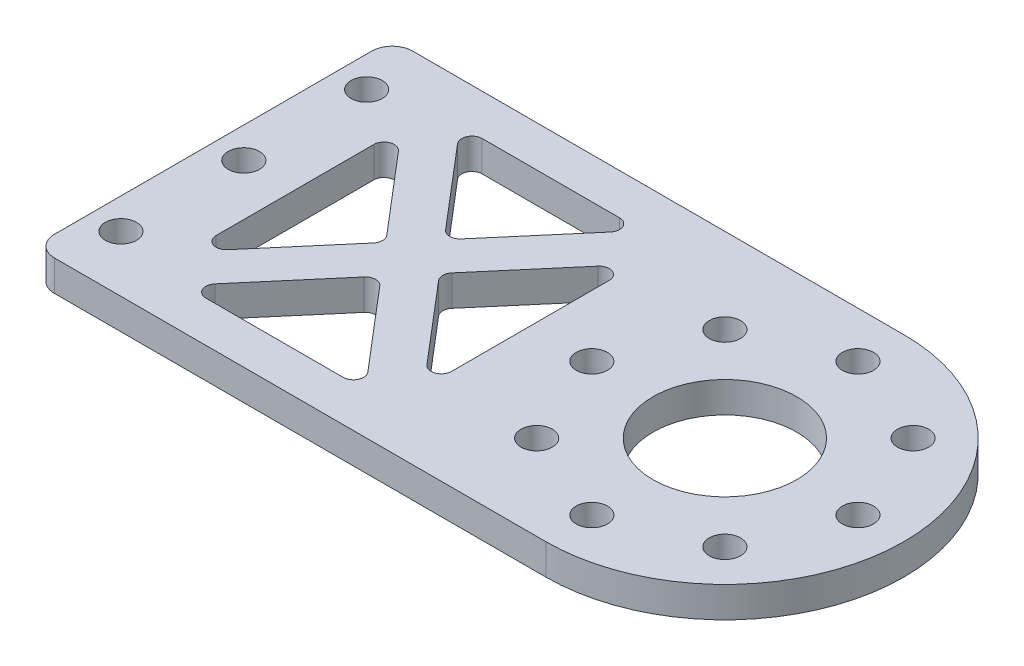
from build123d import *

# Parameters (mm, degrees)
EXTRUDE_1_DEPTH     = 3
SKETCH_2_R          = 7.025
CUT_EXTRUDE_1_DEPTH = 4
SKETCH_4_R          = 1.525
CUT_EXTRUDE_3_DEPTH = 4
FILLET_2_R          = 2
CUT_EXTRUDE_6_DEPTH = 4
SKETCH_10_R         = 1.525
CUT_EXTRUDE_8_DEPTH = 4
FILLET_7_R          = 1


with BuildPart() as part:
    # 草图1 → 凸台-拉伸1 (new body)
    with BuildSketch(Plane(origin=(0, 0, 0), x_dir=(1, 0, 0), z_dir=(0, 1, 0))):
        with BuildLine():
            Line((-25, 17.5), (-25, -17.5))
            Line((-25, -17.5), (25, -17.5))
            ThreePointArc((25, -17.5), (7.5, 0), (25, 17.5))
            Line((25, 17.5), (-25, 17.5))
        make_face()
        with BuildLine():
            ThreePointArc((25, 17.5), (7.5, 0), (25, -17.5))
            Line((25, -17.5), (25, 17.5))
        make_face()
        with BuildLine():
            Line((25, 17.5), (25, -17.5))
            ThreePointArc((25, -17.5), (37.374368671, -12.374368671), (42.5, 0))
            ThreePointArc((42.5, 0), (37.374368671, 12.374368671), (25, 17.5))
        make_face()
    extrude(amount=EXTRUDE_1_DEPTH)

    # 草图2 → 切除-拉伸1 (cut, through all)
    with BuildSketch(Plane(origin=(0, 3, 0), x_dir=(1, 0, 0), z_dir=(0, 1, 0))):
        with Locations((25, 0)):
            Circle(SKETCH_2_R)
    extrude(amount=-CUT_EXTRUDE_1_DEPTH, mode=Mode.SUBTRACT)

    # 草图4 → 切除-拉伸3 (cut, through all)
    with BuildSketch(Plane(origin=(0, 3, 0), x_dir=(1, 0, 0), z_dir=(0, 1, 0))):
        with Locations((25, 13)):
            Circle(SKETCH_4_R)
        with Locations((34.192388155, 9.192388155)):
            Circle(SKETCH_4_R)
        with Locations((38, 0)):
            Circle(SKETCH_4_R)
        with Locations((34.192388155, -9.192388155)):
            Circle(SKETCH_4_R)
        with Locations((25, -13)):
            Circle(SKETCH_4_R)
        with Locations((15.807611845, -9.192388155)):
            Circle(SKETCH_4_R)
        with Locations((12, 0)):
            Circle(SKETCH_4_R)
        with Locations((15.807611845, 9.192388155)):
            Circle(SKETCH_4_R)
    extrude(amount=-CUT_EXTRUDE_3_DEPTH, mode=Mode.SUBTRACT)

    # 圆角2
    fillet_2_edges = [part.edges().sort_by_distance(p)[0] for p in [
        (-25, 1.5, 17.5),
        (-25, 1.5, -17.5),
    ]]
    fillet(fillet_2_edges, radius=FILLET_2_R)

    # 草图7 → 切除-拉伸6 (cut, through all)
    with BuildSketch(Plane(origin=(0, 3, 0), x_dir=(1, 0, 0), z_dir=(0, 1, 0))):
        Polygon((3.372718837, 13.5), (-14.372718837, 13.5), (-5.5, 3.084199626), align=None)
        Polygon((-2.872718837, 0), (6, -10.415800374), (6, 10.415800374), align=None)
        Polygon((-5.5, -3.084199626), (-14.372718837, -13.5), (3.372718837, -13.5), align=None)
        Polygon((-17, 10.415800374), (-17, -10.415800374), (-8.127281163, 0), align=None)
    extrude(amount=-CUT_EXTRUDE_6_DEPTH, mode=Mode.SUBTRACT)

    # 草图10 → 切除-拉伸8 (cut, through all)
    with BuildSketch(Plane(origin=(0, 3, 0), x_dir=(1, 0, 0), z_dir=(0, 1, 0))):
        with Locations((-22, 0)):
            Circle(SKETCH_10_R)
        with Locations((-22, 12)):
            Circle(SKETCH_10_R)
        with Locations((-22, -12)):
            Circle(SKETCH_10_R)
    extrude(amount=-CUT_EXTRUDE_8_DEPTH, mode=Mode.SUBTRACT)

    # 圆角7
    fillet_7_edges = [part.edges().sort_by_distance(p)[0] for p in [
        (-17, 1.5, 10.415800374),
        (-17, 1.5, -10.415800374),
        (-8.127281163, 1.5, 0),
        (-5.5, 1.5, -3.084199626),
        (-14.372718837, 1.5, -13.5),
        (3.372718837, 1.5, -13.5),
        (-14.372718837, 1.5, 13.5),
        (-5.5, 1.5, 3.084199626),
        (3.372718837, 1.5, 13.5),
        (-2.872718837, 1.5, 0),
        (6, 1.5, -10.415800374),
        (6, 1.5, 10.415800374),
    ]]
    fillet(fillet_7_edges, radius=FILLET_7_R)


solid = part.part
